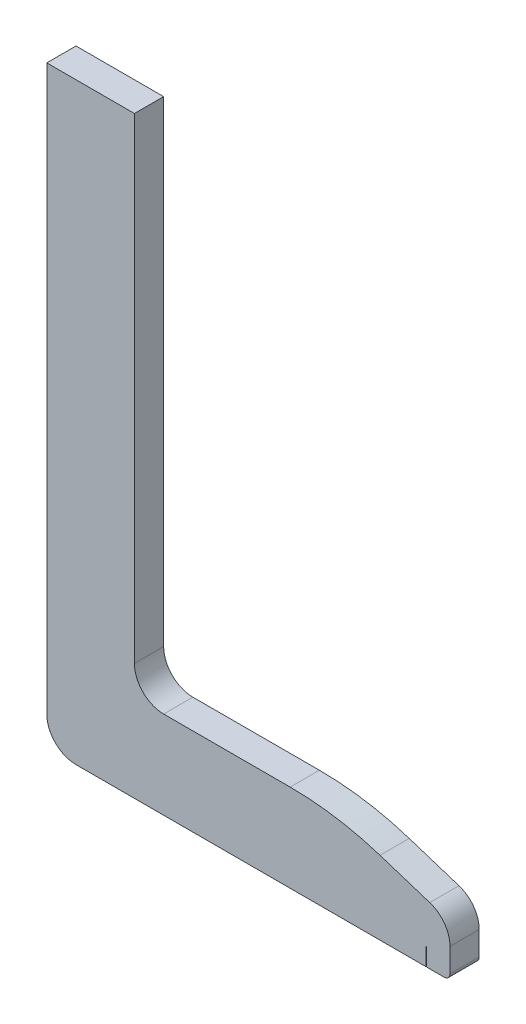
from build123d import *

# Parameters (mm, degrees)
BOSS_EXTRUDE1_DEPTH = 5
SKETCH2_W           = 0.1
SKETCH2_H           = 5
CUT_EXTRUDE2_DEPTH  = 3


with BuildPart() as part:
    # Sketch1 → Boss-Extrude1 (new body)
    with BuildSketch(Plane.XY):
        with BuildLine():
            Line((0, -1), (0, -96.5))
            ThreePointArc((0, -96.5), (1.464466094, -100.035533906), (5, -101.5))
            Line((5, -101.5), (68, -101.5))
            ThreePointArc((68, -101.5), (68.707106781, -101.207106781), (69, -100.5))
            Line((69, -100.5), (69, -96.429996046))
            ThreePointArc((69, -96.429996046), (68.042547906, -93.487580979), (65.53687743, -91.672054499))
            Line((65.53687743, -91.672054499), (57.01873992, -88.920584529))
            ThreePointArc((57.01873992, -88.920584529), (49.429079532, -87.108853154), (41.649965621, -86.5))
            Line((41.649965621, -86.5), (20, -86.5))
            ThreePointArc((20, -86.5), (16.464466094, -85.035533906), (15, -81.5))
            Line((15, -81.5), (15, -61))
            Line((15, -61), (15, 0))
            Line((15, 0), (0, 0))
            Line((0, 0), (0, -1))
        make_face()
    extrude(amount=BOSS_EXTRUDE1_DEPTH)

    # Sketch2 → Cut-Extrude2 (cut)
    with BuildSketch(Plane.XZ.offset(101.5)):
        with Locations((64.9, 2.5)):
            Rectangle(SKETCH2_W, SKETCH2_H)
    extrude(amount=-CUT_EXTRUDE2_DEPTH, mode=Mode.SUBTRACT)


solid = part.part
